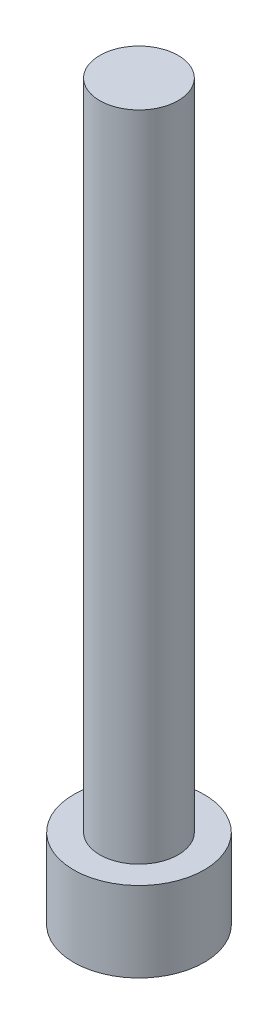
from build123d import *

# Parameters (mm, degrees)
SKETCH1_R           = 2.8575
BOSS_EXTRUDE1_DEPTH = 3.5052
CUT_EXTRUDE1_DEPTH  = 1.9558
SKETCH3_R           = 1.7145
BOSS_EXTRUDE2_DEPTH = 28.575


with BuildPart() as part:
    # Sketch1 → Boss-Extrude1 (new body)
    with BuildSketch(Plane(origin=(0, 0, 0), x_dir=(1, 0, 0), z_dir=(0, 1, 0))):
        Circle(SKETCH1_R)
    extrude(amount=BOSS_EXTRUDE1_DEPTH)

    # Sketch2 → Cut-Extrude1 (cut)
    with BuildSketch(Plane.XZ):
        Polygon((1.603951217, 0), (0.801975608, 1.3890625), (-0.801975608, 1.3890625), (-1.603951217, 0), (-0.801975608, -1.3890625), (0.801975608, -1.3890625), align=None)
    extrude(amount=-CUT_EXTRUDE1_DEPTH, mode=Mode.SUBTRACT)

    # Sketch3 → Boss-Extrude2 (add)
    with BuildSketch(Plane(origin=(0, 3.5052, 0), x_dir=(1, 0, 0), z_dir=(0, 1, 0))):
        Circle(SKETCH3_R)
    extrude(amount=BOSS_EXTRUDE2_DEPTH)


solid = part.part
